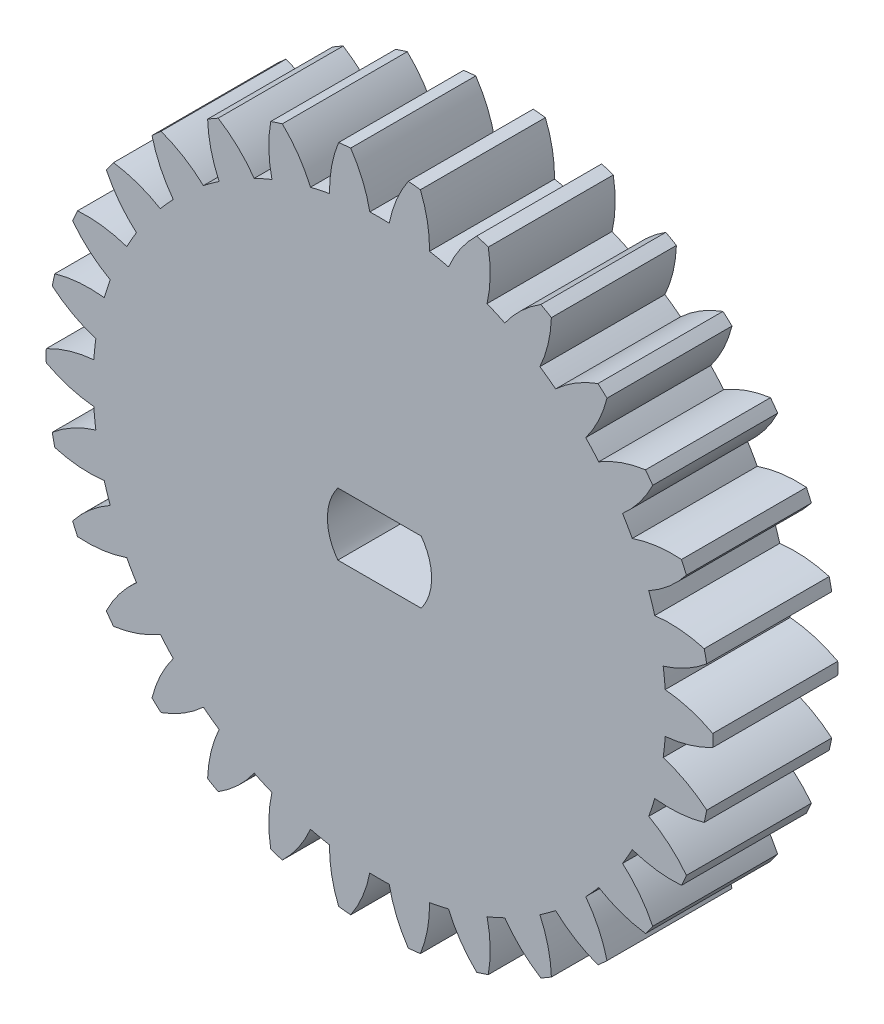
from build123d import *

# Parameters (mm, degrees)
BOSS_EXTRUDE1_DEPTH = 6


with BuildPart() as part:
    # Sketch2 → Boss-Extrude1 (new body)
    with BuildSketch(Plane.XY):
        with BuildLine():
            ThreePointArc((-15.997323333, 0.292653692), (-16, 0), (-15.997323333, -0.292653692))
            ThreePointArc((-15.997323333, -0.292653692), (-14.890017219, -0.746983902), (-13.714564017, -0.972488982))
            ThreePointArc((-13.714564017, -0.972488982), (-13.673681539, -1.437161841), (-13.617059717, -1.900180429))
            ThreePointArc((-13.617059717, -1.900180429), (-14.719941304, -2.365148144), (-15.70858956, -3.039772036))
            ThreePointArc((-15.70858956, -3.039772036), (-15.650361612, -3.326587053), (-15.586897312, -3.612289049))
            ThreePointArc((-15.586897312, -3.612289049), (-14.409327931, -3.826469168), (-13.21267606, -3.802655958))
            ThreePointArc((-13.21267606, -3.802655958), (-13.076076043, -4.248674656), (-12.924424565, -4.689802838))
            ThreePointArc((-12.924424565, -4.689802838), (-13.90653332, -5.373911868), (-14.733315045, -6.23934514))
            ThreePointArc((-14.733315045, -6.23934514), (-14.616727322, -6.507786289), (-14.495249085, -6.774050041))
            ThreePointArc((-14.495249085, -6.774050041), (-13.29888187, -6.73871937), (-12.133330757, -6.466628622))
            ThreePointArc((-12.133330757, -6.466628622), (-11.906983277, -6.8745), (-11.666930042, -7.274458358))
            ThreePointArc((-11.666930042, -7.274458358), (-12.485343098, -8.147809856), (-13.114123965, -9.166228921))
            ThreePointArc((-13.114123965, -9.166228921), (-12.94427191, -9.404564037), (-12.770088917, -9.639752541))
            ThreePointArc((-12.770088917, -9.639752541), (-11.607210855, -9.356455199), (-10.523700679, -8.847978584))
            ThreePointArc((-10.523700679, -8.847978584), (-10.217498205, -9.199876707), (-9.899534691, -9.541185141))
            ThreePointArc((-9.899534691, -9.541185141), (-10.518483472, -10.565609456), (-10.921782738, -11.692504514))
            ThreePointArc((-10.921782738, -11.692504514), (-10.706089702, -11.890317208), (-10.486814585, -12.084151598))
            ThreePointArc((-10.486814585, -12.084151598), (-9.408249029, -11.565269039), (-8.454134382, -10.842629425))
            ThreePointArc((-8.454134382, -10.842629425), (-8.081459434, -11.123174656), (-7.699482172, -11.39091635))
            ThreePointArc((-7.699482172, -11.39091635), (-8.091915645, -12.521641223), (-8.252107198, -13.707761553))
            ThreePointArc((-8.252107198, -13.707761553), (-8, -13.856406461), (-7.745216135, -14.000415245))
            ThreePointArc((-7.745216135, -14.000415245), (-6.798101574, -13.268625126), (-6.015081845, -12.363405332))
            ThreePointArc((-6.015081845, -12.363405332), (-5.592222106, -12.560336497), (-5.162925335, -12.742809854))
            ThreePointArc((-5.162925335, -12.742809854), (-5.311692275, -13.930417183), (-5.221774975, -15.123923635))
            ThreePointArc((-5.221774975, -15.123923635), (-4.94427191, -15.216904261), (-4.665114574, -15.304793563))
            ThreePointArc((-4.665114574, -15.304793563), (-3.890844459, -14.392078624), (-3.313141369, -13.343841099))
            ThreePointArc((-3.313141369, -13.343841099), (-2.858577837, -13.448551362), (-2.400723887, -13.537781422))
            ThreePointArc((-2.400723887, -13.537781422), (-2.299322464, -14.730367067), (-1.963226128, -15.879097681))
            ThreePointArc((-1.963226128, -15.879097681), (-1.672455412, -15.912350326), (-1.38112512, -15.940278962))
            ThreePointArc((-1.38112512, -15.940278962), (-0.813538771, -14.886529226), (-0.466400716, -13.741086979))
            ThreePointArc((-0.466400716, -13.741086979), (0, -13.749), (0.466400716, -13.741086979))
            ThreePointArc((0.466400716, -13.741086979), (0.813538771, -14.886529226), (1.38112512, -15.940278962))
            ThreePointArc((1.38112512, -15.940278962), (1.672455412, -15.912350326), (1.963226128, -15.879097681))
            ThreePointArc((1.963226128, -15.879097681), (2.299322464, -14.730367067), (2.400723887, -13.537781422))
            ThreePointArc((2.400723887, -13.537781422), (2.858577837, -13.448551362), (3.313141369, -13.343841099))
            ThreePointArc((3.313141369, -13.343841099), (3.890844459, -14.392078624), (4.665114574, -15.304793563))
            ThreePointArc((4.665114574, -15.304793563), (4.94427191, -15.216904261), (5.221774975, -15.123923635))
            ThreePointArc((5.221774975, -15.123923635), (5.311692275, -13.930417183), (5.162925335, -12.742809854))
            ThreePointArc((5.162925335, -12.742809854), (5.592222106, -12.560336497), (6.015081845, -12.363405332))
            ThreePointArc((6.015081845, -12.363405332), (6.798101574, -13.268625126), (7.745216135, -14.000415245))
            ThreePointArc((7.745216135, -14.000415245), (8, -13.856406461), (8.252107198, -13.707761553))
            ThreePointArc((8.252107198, -13.707761553), (8.091915645, -12.521641223), (7.699482172, -11.39091635))
            ThreePointArc((7.699482172, -11.39091635), (8.081459434, -11.123174656), (8.454134382, -10.842629425))
            ThreePointArc((8.454134382, -10.842629425), (9.408249029, -11.565269039), (10.486814585, -12.084151598))
            ThreePointArc((10.486814585, -12.084151598), (10.706089702, -11.890317208), (10.921782738, -11.692504514))
            ThreePointArc((10.921782738, -11.692504514), (10.518483472, -10.565609456), (9.899534691, -9.541185141))
            ThreePointArc((9.899534691, -9.541185141), (10.217498205, -9.199876707), (10.523700679, -8.847978584))
            ThreePointArc((10.523700679, -8.847978584), (11.607210855, -9.356455199), (12.770088917, -9.639752541))
            ThreePointArc((12.770088917, -9.639752541), (12.94427191, -9.404564037), (13.114123965, -9.166228921))
            ThreePointArc((13.114123965, -9.166228921), (12.485343098, -8.147809856), (11.666930042, -7.274458358))
            ThreePointArc((11.666930042, -7.274458358), (11.906983277, -6.8745), (12.133330757, -6.466628622))
            ThreePointArc((12.133330757, -6.466628622), (13.29888187, -6.73871937), (14.495249085, -6.774050041))
            ThreePointArc((14.495249085, -6.774050041), (14.616727322, -6.507786289), (14.733315045, -6.23934514))
            ThreePointArc((14.733315045, -6.23934514), (13.90653332, -5.373911868), (12.924424565, -4.689802838))
            ThreePointArc((12.924424565, -4.689802838), (13.076076043, -4.248674656), (13.21267606, -3.802655958))
            ThreePointArc((13.21267606, -3.802655958), (14.409327931, -3.826469168), (15.586897312, -3.612289049))
            ThreePointArc((15.586897312, -3.612289049), (15.650361612, -3.326587053), (15.70858956, -3.039772036))
            ThreePointArc((15.70858956, -3.039772036), (14.719941304, -2.365148144), (13.617059717, -1.900180429))
            ThreePointArc((13.617059717, -1.900180429), (13.673681539, -1.437161841), (13.714564017, -0.972488982))
            ThreePointArc((13.714564017, -0.972488982), (14.890017219, -0.746983902), (15.997323333, -0.292653692))
            ThreePointArc((15.997323333, -0.292653692), (16, 0), (15.997323333, 0.292653692))
            ThreePointArc((15.997323333, 0.292653692), (14.890017219, 0.746983902), (13.714564017, 0.972488982))
            ThreePointArc((13.714564017, 0.972488982), (13.673681539, 1.437161841), (13.617059717, 1.900180429))
            ThreePointArc((13.617059717, 1.900180429), (14.719941304, 2.365148144), (15.70858956, 3.039772036))
            ThreePointArc((15.70858956, 3.039772036), (15.650361612, 3.326587053), (15.586897312, 3.612289049))
            ThreePointArc((15.586897312, 3.612289049), (14.409327931, 3.826469168), (13.21267606, 3.802655958))
            ThreePointArc((13.21267606, 3.802655958), (13.076076043, 4.248674656), (12.924424565, 4.689802838))
            ThreePointArc((12.924424565, 4.689802838), (13.90653332, 5.373911868), (14.733315045, 6.23934514))
            ThreePointArc((14.733315045, 6.23934514), (14.616727322, 6.507786289), (14.495249085, 6.774050041))
            ThreePointArc((14.495249085, 6.774050041), (13.29888187, 6.73871937), (12.133330757, 6.466628622))
            ThreePointArc((12.133330757, 6.466628622), (11.906983277, 6.8745), (11.666930042, 7.274458358))
            ThreePointArc((11.666930042, 7.274458358), (12.485343098, 8.147809856), (13.114123965, 9.166228921))
            ThreePointArc((13.114123965, 9.166228921), (12.94427191, 9.404564037), (12.770088917, 9.639752541))
            ThreePointArc((12.770088917, 9.639752541), (11.607210855, 9.356455199), (10.523700679, 8.847978584))
            ThreePointArc((10.523700679, 8.847978584), (10.217498205, 9.199876707), (9.899534691, 9.541185141))
            ThreePointArc((9.899534691, 9.541185141), (10.518483472, 10.565609456), (10.921782738, 11.692504514))
            ThreePointArc((10.921782738, 11.692504514), (10.706089702, 11.890317208), (10.486814585, 12.084151598))
            ThreePointArc((10.486814585, 12.084151598), (9.408249029, 11.565269039), (8.454134382, 10.842629425))
            ThreePointArc((8.454134382, 10.842629425), (8.081459434, 11.123174656), (7.699482172, 11.39091635))
            ThreePointArc((7.699482172, 11.39091635), (8.091915645, 12.521641223), (8.252107198, 13.707761553))
            ThreePointArc((8.252107198, 13.707761553), (8, 13.856406461), (7.745216135, 14.000415245))
            ThreePointArc((7.745216135, 14.000415245), (6.798101574, 13.268625126), (6.015081845, 12.363405332))
            ThreePointArc((6.015081845, 12.363405332), (5.592222106, 12.560336497), (5.162925335, 12.742809854))
            ThreePointArc((5.162925335, 12.742809854), (5.311692275, 13.930417183), (5.221774975, 15.123923635))
            ThreePointArc((5.221774975, 15.123923635), (4.94427191, 15.216904261), (4.665114574, 15.304793563))
            ThreePointArc((4.665114574, 15.304793563), (3.890844459, 14.392078624), (3.313141369, 13.343841099))
            ThreePointArc((3.313141369, 13.343841099), (2.858577837, 13.448551362), (2.400723887, 13.537781422))
            ThreePointArc((2.400723887, 13.537781422), (2.299322464, 14.730367067), (1.963226128, 15.879097681))
            ThreePointArc((1.963226128, 15.879097681), (1.672455412, 15.912350326), (1.38112512, 15.940278962))
            ThreePointArc((1.38112512, 15.940278962), (0.813538771, 14.886529226), (0.466400716, 13.741086979))
            ThreePointArc((0.466400716, 13.741086979), (0, 13.749), (-0.466400716, 13.741086979))
            ThreePointArc((-0.466400716, 13.741086979), (-0.813538771, 14.886529226), (-1.38112512, 15.940278962))
            ThreePointArc((-1.38112512, 15.940278962), (-1.672455412, 15.912350326), (-1.963226128, 15.879097681))
            ThreePointArc((-1.963226128, 15.879097681), (-2.299322464, 14.730367067), (-2.400723887, 13.537781422))
            ThreePointArc((-2.400723887, 13.537781422), (-2.858577837, 13.448551362), (-3.313141369, 13.343841099))
            ThreePointArc((-3.313141369, 13.343841099), (-3.890844459, 14.392078624), (-4.665114574, 15.304793563))
            ThreePointArc((-4.665114574, 15.304793563), (-4.94427191, 15.216904261), (-5.221774975, 15.123923635))
            ThreePointArc((-5.221774975, 15.123923635), (-5.311692275, 13.930417183), (-5.162925335, 12.742809854))
            ThreePointArc((-5.162925335, 12.742809854), (-5.592222106, 12.560336497), (-6.015081845, 12.363405332))
            ThreePointArc((-6.015081845, 12.363405332), (-6.798101574, 13.268625126), (-7.745216135, 14.000415245))
            ThreePointArc((-7.745216135, 14.000415245), (-8, 13.856406461), (-8.252107198, 13.707761553))
            ThreePointArc((-8.252107198, 13.707761553), (-8.091915645, 12.521641223), (-7.699482172, 11.39091635))
            ThreePointArc((-7.699482172, 11.39091635), (-8.081459434, 11.123174656), (-8.454134382, 10.842629425))
            ThreePointArc((-8.454134382, 10.842629425), (-9.408249029, 11.565269039), (-10.486814585, 12.084151598))
            ThreePointArc((-10.486814585, 12.084151598), (-10.706089702, 11.890317208), (-10.921782738, 11.692504514))
            ThreePointArc((-10.921782738, 11.692504514), (-10.518483472, 10.565609456), (-9.899534691, 9.541185141))
            ThreePointArc((-9.899534691, 9.541185141), (-10.217498205, 9.199876707), (-10.523700679, 8.847978584))
            ThreePointArc((-10.523700679, 8.847978584), (-11.607210855, 9.356455199), (-12.770088917, 9.639752541))
            ThreePointArc((-12.770088917, 9.639752541), (-12.94427191, 9.404564037), (-13.114123965, 9.166228921))
            ThreePointArc((-13.114123965, 9.166228921), (-12.485343098, 8.147809856), (-11.666930042, 7.274458358))
            ThreePointArc((-11.666930042, 7.274458358), (-11.906983277, 6.8745), (-12.133330757, 6.466628622))
            ThreePointArc((-12.133330757, 6.466628622), (-13.29888187, 6.73871937), (-14.495249085, 6.774050041))
            ThreePointArc((-14.495249085, 6.774050041), (-14.616727322, 6.507786289), (-14.733315045, 6.23934514))
            ThreePointArc((-14.733315045, 6.23934514), (-13.90653332, 5.373911868), (-12.924424565, 4.689802838))
            ThreePointArc((-12.924424565, 4.689802838), (-13.076076043, 4.248674656), (-13.21267606, 3.802655958))
            ThreePointArc((-13.21267606, 3.802655958), (-14.409327931, 3.826469168), (-15.586897312, 3.612289049))
            ThreePointArc((-15.586897312, 3.612289049), (-15.650361612, 3.326587053), (-15.70858956, 3.039772036))
            ThreePointArc((-15.70858956, 3.039772036), (-14.719941304, 2.365148144), (-13.617059717, 1.900180429))
            ThreePointArc((-13.617059717, 1.900180429), (-13.673681539, 1.437161841), (-13.714564017, 0.972488982))
            ThreePointArc((-13.714564017, 0.972488982), (-14.890017219, 0.746983902), (-15.997323333, 0.292653692))
        make_face()
        with BuildLine():
            Line((-2, 1.5), (2, 1.5))
            ThreePointArc((2, 1.5), (2.5, 0), (2, -1.5))
            Line((2, -1.5), (-2, -1.5))
            ThreePointArc((-2, -1.5), (-2.5, 0), (-2, 1.5))
        make_face(mode=Mode.SUBTRACT)
    extrude(amount=BOSS_EXTRUDE1_DEPTH)


solid = part.part
